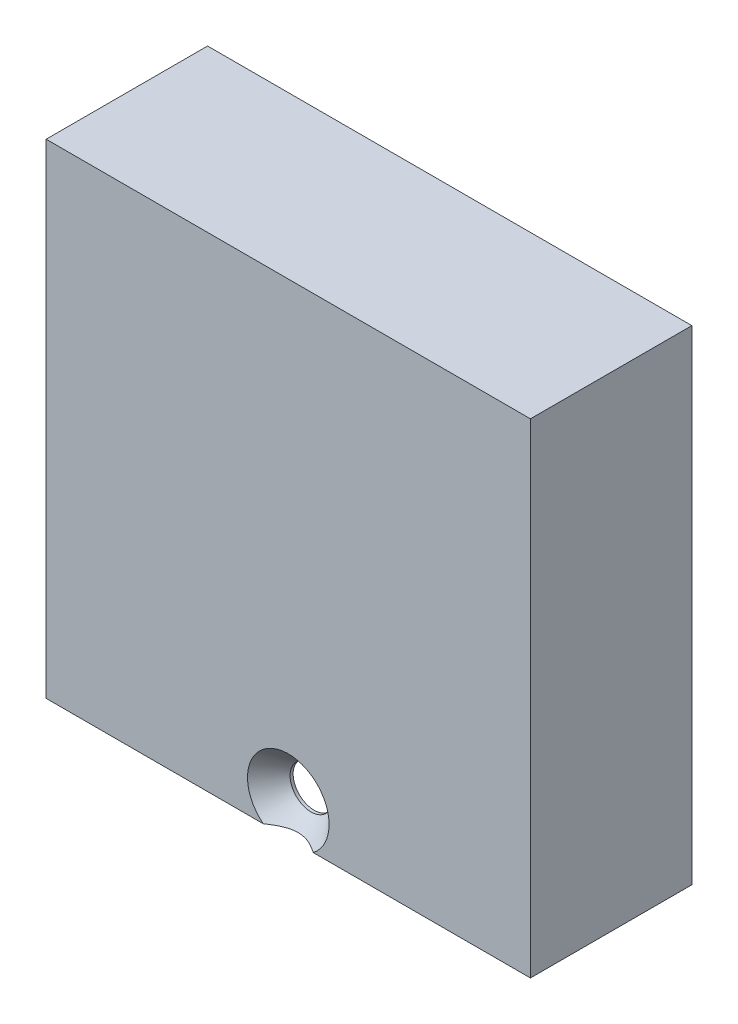
from build123d import *

# Parameters (mm, degrees)
ESQUISSE1_W                                       = 30
ESQUISSE1_H                                       = 30
MAIN_DEPTH                                        = 10
MAIN_FIX_DEPTH                                    = 28.5
BOSS_EXTRU_2_DEPTH                                = 8.4
BOSS_EXTRU_3_DEPTH                                = 1
FRAISAGE_POUR_VIS_T_TE_FRAIS_E_BOMB_E_D           = 2.5999948
FRAISAGE_POUR_VIS_T_TE_FRAIS_E_BOMB_E_CSINK_D     = 5.0546
FRAISAGE_POUR_VIS_T_TE_FRAIS_E_BOMB_E_CSINK_ANGLE = 82


with BuildPart() as part:
    # Esquisse1 → Main (new body)
    with BuildSketch(Plane.XY):
        with Locations((15, 15)):
            Rectangle(ESQUISSE1_W, ESQUISSE1_H)
    extrude(amount=MAIN_DEPTH)

    # Esquisse2 → Main Fix (cut)
    with BuildSketch(Plane.XZ):
        Polygon((2.75, 0), (2.75, 5.2), (3.35, 5.2), (3.35, 6.2), (2.75, 6.2), (2.75, 8.4), (27.25, 8.4), (27.25, 6.2), (26.65, 6.2), (26.65, 5.2), (27.25, 5.2), (27.25, 0), align=None)
    extrude(amount=-MAIN_FIX_DEPTH, mode=Mode.SUBTRACT)

    # Esquisse4 → Boss.-Extru.2 (add)
    with BuildSketch(Plane(origin=(0, 0, 8.4), x_dir=(-1, 0, 0), z_dir=(0, 0, -1))):
        with BuildLine():
            Line((-27.25, 15.5), (-27.25, 28.5))
            Line((-27.25, 28.5), (-2.75, 28.5))
            Line((-2.75, 28.5), (-2.75, 15.5))
            ThreePointArc((-2.75, 15.5), (-15, 27.75), (-27.25, 15.5))
        make_face()
    extrude(amount=BOSS_EXTRU_2_DEPTH)

    # Esquisse5 → Boss.-Extru.3 (add)
    with BuildSketch(Plane(origin=(0, 0, 5.2), x_dir=(-1, 0, 0), z_dir=(0, 0, -1))):
        with BuildLine():
            Line((-3.35, 13.970294146), (0, 13.970294146))
            Line((0, 13.970294146), (0, 30))
            Line((0, 30), (-30, 30))
            Line((-30, 30), (-30, 13.970294146))
            Line((-30, 13.970294146), (-26.65, 13.970294146))
            ThreePointArc((-26.65, 13.970294146), (-15, 27.25), (-3.35, 13.970294146))
        make_face()
    extrude(amount=-BOSS_EXTRU_3_DEPTH)

    # Fraisage pour vis à tête fraisée bombée #33 (through all)
    with Locations(Plane.XY.offset(10)):
        with Locations((15, 2)):
            CounterSinkHole(FRAISAGE_POUR_VIS_T_TE_FRAIS_E_BOMB_E_D / 2, FRAISAGE_POUR_VIS_T_TE_FRAIS_E_BOMB_E_CSINK_D / 2, counter_sink_angle=FRAISAGE_POUR_VIS_T_TE_FRAIS_E_BOMB_E_CSINK_ANGLE)


solid = part.part
